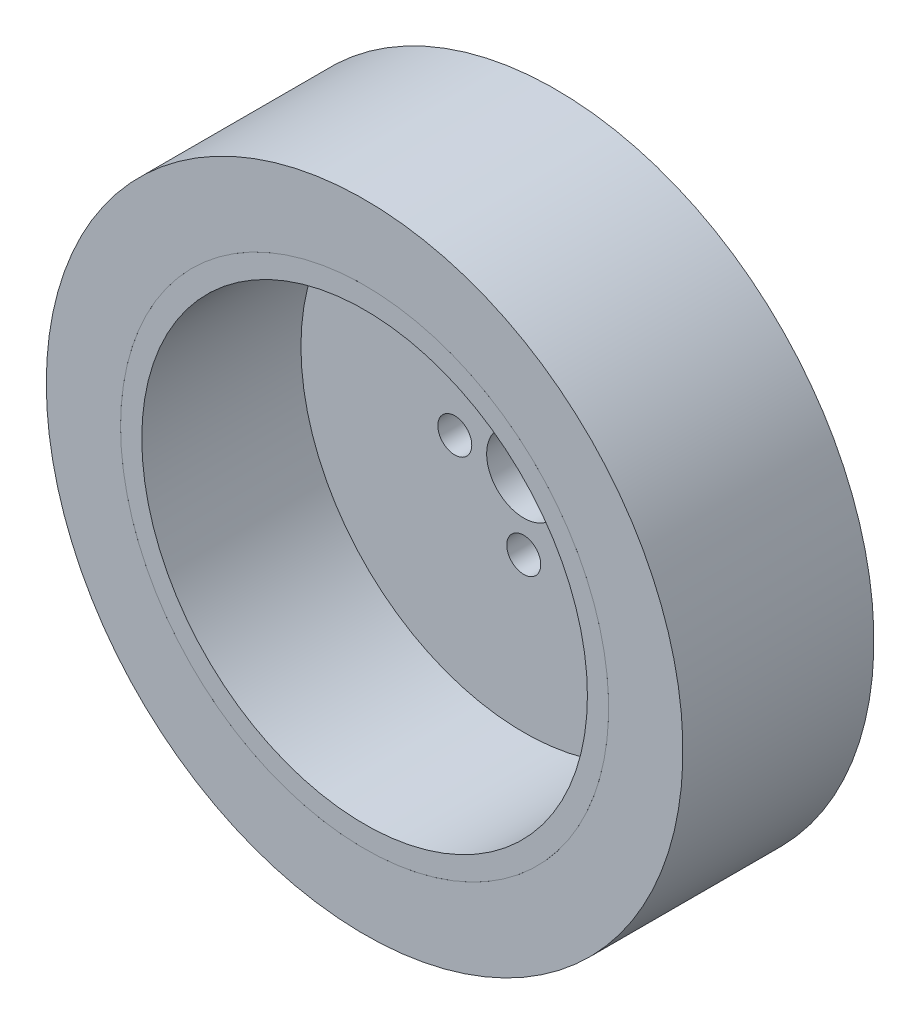
from build123d import *

# Parameters (mm, degrees)
SKETCH_2_R          = 1.6
CUT_EXTRUDE_1_DEPTH = 10
SKETCH_3_W          = 6.999
SKETCH_3_H          = 18


with BuildPart() as part:
    # 草图1 → 旋转1 (revolve)
    with BuildSketch(Plane(origin=(0, 0, 0), x_dir=(1, 0, 0), z_dir=(0, 1, 0))):
        Polygon((-3.5, 0), (-23, 0), (-23, -18), (-21, -18), (-21, -3), (-3.5, -3), align=None)
    revolve(axis=Axis((0, 0, 0), (0, 0, 1)))

    # 草图2 → 切除-拉伸1 (cut)
    with BuildSketch(Plane(origin=(0, 0, 0), x_dir=(-1, 0, 0), z_dir=(0, 0, -1))):
        with Locations((6.5, 0)):
            Circle(SKETCH_2_R)
        with Locations((0, -6.5)):
            Circle(SKETCH_2_R)
        with Locations((-6.5, 0)):
            Circle(SKETCH_2_R)
        with Locations((0, 6.5)):
            Circle(SKETCH_2_R)
    extrude(amount=-CUT_EXTRUDE_1_DEPTH, mode=Mode.SUBTRACT)


with BuildPart() as body_2:
    # 草图3 → 旋转2 (revolve)
    with BuildSketch(Plane(origin=(0, 0, 0), x_dir=(1, 0, 0), z_dir=(0, 1, 0))):
        with Locations((-26.5005, -9)):
            Rectangle(SKETCH_3_W, SKETCH_3_H)
    revolve(axis=Axis((0, 0, 0), (0, 0, 1)))


solid = Compound([part.part, body_2.part])
